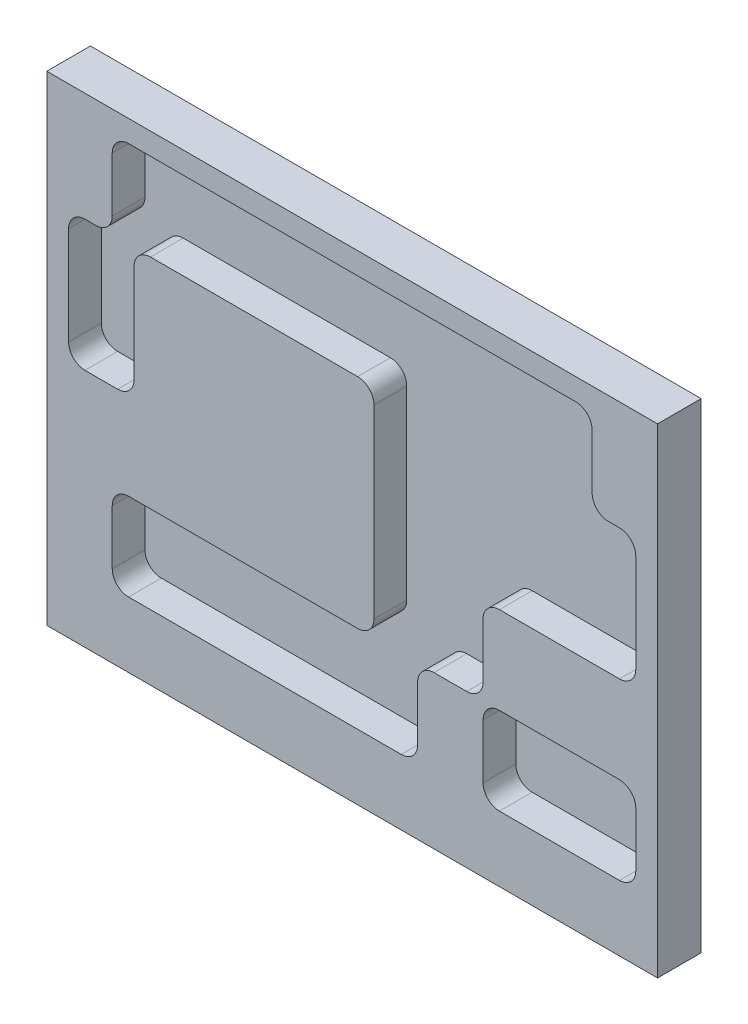
from build123d import *

# Parameters (mm, degrees)
SKETCH1_W           = 177.8
SKETCH1_H           = 139.7
BOSS_EXTRUDE1_DEPTH = 12.7
CUT_EXTRUDE1_DEPTH  = 9.525


with BuildPart() as part:
    # Sketch1 → Boss-Extrude1 (new body)
    with BuildSketch(Plane.XY):
        Rectangle(SKETCH1_W, SKETCH1_H)
    extrude(amount=BOSS_EXTRUDE1_DEPTH)

    # Sketch2 → Cut-Extrude1 (cut)
    with BuildSketch(Plane.XY.offset(12.7)):
        with BuildLine():
            Line((-65.0875, 63.5), (65.0875, 63.5))
            ThreePointArc((65.0875, 63.5), (68.455096045, 62.105096045), (69.85, 58.7375))
            Line((69.85, 58.7375), (69.85, 42.8625))
            ThreePointArc((69.85, 42.8625), (71.244903955, 39.494903955), (74.6125, 38.1))
            Line((74.6125, 38.1), (77.7875, 38.1))
            ThreePointArc((77.7875, 38.1), (81.155096045, 36.705096045), (82.55, 33.3375))
            Line((82.55, 33.3375), (82.55, 4.7625))
            ThreePointArc((82.55, 4.7625), (81.155096045, 1.394903955), (77.7875, 0))
            Line((77.7875, 0), (42.8625, 0))
            ThreePointArc((42.8625, 0), (39.494903955, -1.394903955), (38.1, -4.7625))
            Line((38.1, -4.7625), (38.1, -20.6375))
            ThreePointArc((38.1, -20.6375), (36.705096045, -24.005096045), (33.3375, -25.4))
            Line((33.3375, -25.4), (23.8125, -25.4))
            ThreePointArc((23.8125, -25.4), (20.444903955, -26.794903955), (19.05, -30.1625))
            Line((19.05, -30.1625), (19.05, -46.0375))
            ThreePointArc((19.05, -46.0375), (17.655096045, -49.405096045), (14.2875, -50.8))
            Line((14.2875, -50.8), (-65.0875, -50.8))
            ThreePointArc((-65.0875, -50.8), (-68.455096045, -49.405096045), (-69.85, -46.0375))
            Line((-69.85, -46.0375), (-69.85, -30.1625))
            ThreePointArc((-69.85, -30.1625), (-68.455096045, -26.794903955), (-65.0875, -25.4))
            Line((-65.0875, -25.4), (1.5875, -25.4))
            ThreePointArc((1.5875, -25.4), (4.955096045, -24.005096045), (6.35, -20.6375))
            Line((6.35, -20.6375), (6.35, 0))
            Line((6.35, 0), (6.35, 33.3375))
            ThreePointArc((6.35, 33.3375), (4.955096045, 36.705096045), (1.5875, 38.1))
            Line((1.5875, 38.1), (-58.7375, 38.1))
            ThreePointArc((-58.7375, 38.1), (-62.105096045, 36.705096045), (-63.5, 33.3375))
            Line((-63.5, 33.3375), (-63.5, 4.7625))
            ThreePointArc((-63.5, 4.7625), (-64.894903955, 1.394903955), (-68.2625, 0))
            Line((-68.2625, 0), (-77.7875, 0))
            ThreePointArc((-77.7875, 0), (-81.155096045, 1.394903955), (-82.55, 4.7625))
            Line((-82.55, 4.7625), (-82.55, 33.3375))
            ThreePointArc((-82.55, 33.3375), (-81.155096045, 36.705096045), (-77.7875, 38.1))
            Line((-77.7875, 38.1), (-74.6125, 38.1))
            ThreePointArc((-74.6125, 38.1), (-71.244903955, 39.494903955), (-69.85, 42.8625))
            Line((-69.85, 42.8625), (-69.85, 58.7375))
            ThreePointArc((-69.85, 58.7375), (-68.455096045, 62.105096045), (-65.0875, 63.5))
        make_face()
        with BuildLine():
            Line((42.8625, -25.4), (77.7875, -25.4))
            ThreePointArc((77.7875, -25.4), (81.155096045, -26.794903955), (82.55, -30.1625))
            Line((82.55, -30.1625), (82.55, -46.0375))
            ThreePointArc((82.55, -46.0375), (81.155096045, -49.405096045), (77.7875, -50.8))
            Line((77.7875, -50.8), (42.8625, -50.8))
            ThreePointArc((42.8625, -50.8), (39.494903955, -49.405096045), (38.1, -46.0375))
            Line((38.1, -46.0375), (38.1, -30.1625))
            ThreePointArc((38.1, -30.1625), (39.494903955, -26.794903955), (42.8625, -25.4))
        make_face()
    extrude(amount=-CUT_EXTRUDE1_DEPTH, mode=Mode.SUBTRACT)


solid = part.part
